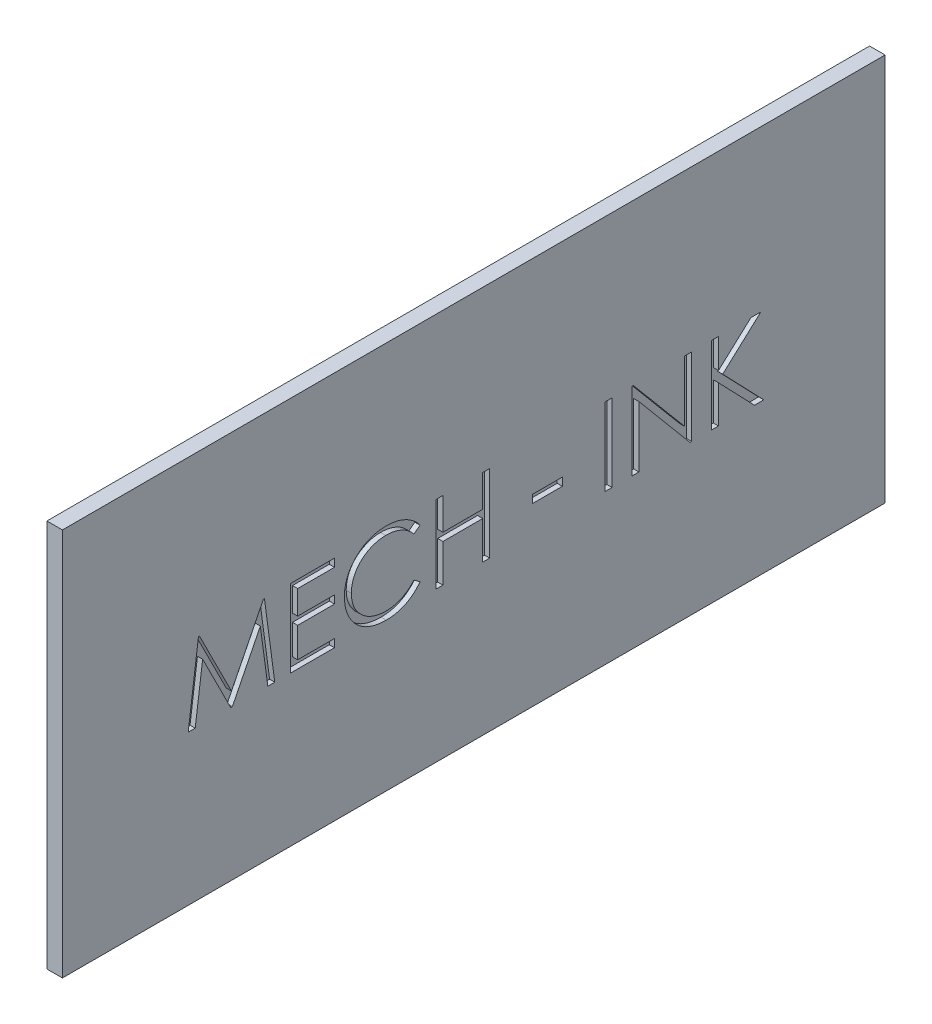
from build123d import *

# Parameters (mm, degrees)
CROQUIS1_W              = 159.01
CROQUIS1_H              = 75
SALIENTE_EXTRUIR1_DEPTH = 3
CROQUIS2_W              = 5.769230769
CROQUIS2_H              = 1.538461538
CROQUIS2_W_2            = 1.346153846
CROQUIS2_H_2            = 15
CORTAR_EXTRUIR1_DEPTH   = 1


with BuildPart() as part:
    # Croquis1 → Saliente-Extruir1 (new body)
    with BuildSketch(Plane(origin=(0, 0, 0), x_dir=(0, 0, -1), z_dir=(1, 0, 0))):
        Rectangle(CROQUIS1_W, CROQUIS1_H)
    extrude(amount=SALIENTE_EXTRUIR1_DEPTH)

    # Croquis2 → Cortar-Extruir1 (cut)
    with BuildSketch(Plane(origin=(3, 0, 0), x_dir=(0, 0, -1), z_dir=(1, 0, 0))):
        Polygon((-55.192307692, -8.506703652), (-53.212139423, 6.493296348), (-53.019831731, 6.493296348), (-46.826923077, -5.81439596), (-40.652043269, 6.493296348), (-40.459735577, 6.493296348), (-38.461538462, -8.506703652), (-39.807692308, -8.506703652), (-41.25, 2.277551155), (-46.661658654, -8.506703652), (-46.968149038, -8.506703652), (-52.403846154, 2.31060404), (-53.837139423, -8.506703652), align=None)
        Polygon((-35.384615385, 6.493296348), (-26.923076923, 6.493296348), (-26.923076923, 4.954834809), (-34.038461538, 4.954834809), (-34.038461538, 0.339450194), (-26.923076923, 0.339450194), (-26.923076923, -1.199011345), (-34.038461538, -1.199011345), (-34.038461538, -6.968242114), (-26.923076923, -6.968242114), (-26.923076923, -8.506703652), (-35.384615385, -8.506703652), align=None)
        with BuildLine():
            Line((-10.384615385, 3.740892502), (-11.5625, 2.839450194))
            add(Edge.make_bspline(
                [(-11.5625, 2.839450194), (-11.646525236, 2.939590065), (-11.813442865, 3.138519703), (-12.081982304, 3.417860608), (-12.361846488, 3.679568871), (-12.652928436, 3.924891213), (-12.96046752, 4.14524878), (-13.2770138, 4.352124936), (-13.607862565, 4.537558098), (-14.065369999, 4.762399467), (-14.663860778, 4.997025846), (-15.417267231, 5.19375398), (-16.203743367, 5.31898759), (-16.740304508, 5.332551196), (-17.013221154, 5.339450194)],
                knots=[0, 0, 0, 0, 0.757959112, 1.505699292, 2.245454638, 2.979532153, 3.711538275, 4.438200793, 5.171680507, 5.909471876, 7.393775596, 8.890124382, 10.418191784, 12, 12, 12, 12], degree=3))
            add(Edge.make_bspline(
                [(-17.013221154, 5.339450194), (-17.163578151, 5.337718926), (-17.462896691, 5.334272458), (-17.907104434, 5.288804778), (-18.34301751, 5.224899593), (-18.770352366, 5.130076779), (-19.188565045, 5.010194126), (-19.600389625, 4.866942352), (-19.999863625, 4.689707324), (-20.392513217, 4.493814781), (-20.768709835, 4.272554303), (-21.12466004, 4.031211367), (-21.459065617, 3.772486668), (-21.772191098, 3.495410498), (-22.06435659, 3.201230667), (-22.333445065, 2.88681206), (-22.578525395, 2.553159888), (-22.804455502, 2.204673856), (-23.006795788, 1.842369034), (-23.176209557, 1.464904447), (-23.326231509, 1.078744005), (-23.444942549, 0.679524744), (-23.538904764, 0.270055748), (-23.603737607, -0.150761915), (-23.648688198, -0.582049113), (-23.652117527, -0.874374738), (-23.653846154, -1.021727691)],
                knots=[0, 0, 0, 0, 1.054917814, 2.100044995, 3.131103042, 4.146048494, 5.169673617, 6.183595914, 7.203665975, 8.234915748, 9.262203917, 10.264457458, 11.251630812, 12.227803204, 13.197192746, 14.159520551, 15.12972552, 16.100847026, 17.073214652, 18.039054194, 19.002613845, 19.979014051, 20.95965708, 21.949030935, 22.966165397, 24, 24, 24, 24], degree=3))
            add(Edge.make_bspline(
                [(-23.653846154, -1.021727691), (-23.648438358, -1.243433348), (-23.637820868, -1.678722997), (-23.543328008, -2.316311328), (-23.39973476, -2.927114215), (-23.184525144, -3.50731354), (-22.919157785, -4.064063646), (-22.583840878, -4.587944446), (-22.195484289, -5.08687258), (-21.74859392, -5.549056641), (-21.25828328, -5.971258321), (-20.732220802, -6.343046528), (-20.171716712, -6.652967453), (-19.582959725, -6.910864366), (-18.961419237, -7.109107485), (-18.308212941, -7.248668014), (-17.624761533, -7.339705931), (-17.157749819, -7.348421737), (-16.920072115, -7.352857498)],
                knots=[0, 0, 0, 0, 1.029171465, 2.020641659, 2.987623507, 3.938342917, 4.889210282, 5.84687017, 6.821220943, 7.821438502, 8.827599549, 9.822697543, 10.807740252, 11.797342354, 12.80366471, 13.83203677, 14.896651826, 16, 16, 16, 16], degree=3))
            add(Edge.make_bspline(
                [(-16.920072115, -7.352857498), (-16.658203448, -7.345619871), (-16.142783267, -7.331374489), (-15.386920297, -7.210691992), (-14.663338444, -7.015015202), (-13.971998788, -6.741166963), (-13.314850304, -6.385172872), (-12.690864617, -5.95361054), (-12.099515029, -5.442374829), (-11.74392382, -5.052018565), (-11.5625, -4.852857498)],
                knots=[0, 0, 0, 0, 1.028121516, 2.023589091, 2.998037872, 3.967518031, 4.937445131, 5.927275754, 6.942489185, 8, 8, 8, 8], degree=3))
            Line((-11.5625, -4.852857498), (-10.384615385, -5.745285383))
            add(Edge.make_bspline(
                [(-10.384615385, -5.745285383), (-10.479407284, -5.867593034), (-10.668537035, -6.11162249), (-10.974785679, -6.455644103), (-11.297402668, -6.779232826), (-11.638784283, -7.079779774), (-11.995003389, -7.363298913), (-12.372456157, -7.621735333), (-12.766180582, -7.858696265), (-13.174842634, -8.075668799), (-13.598008118, -8.268171286), (-14.035169982, -8.432973148), (-14.484443877, -8.57493696), (-14.945850341, -8.691730975), (-15.420346442, -8.782892763), (-15.906219902, -8.843834226), (-16.404519368, -8.885585288), (-16.740696887, -8.889390642), (-16.911057692, -8.891319037)],
                knots=[0, 0, 0, 0, 0.986787822, 1.968848986, 2.935600012, 3.899624008, 4.868462664, 5.837806735, 6.815139263, 7.798259679, 8.787526145, 9.778297419, 10.776456485, 11.791383307, 12.812564526, 13.85620153, 14.913611965, 16, 16, 16, 16], degree=3))
            add(Edge.make_bspline(
                [(-16.911057692, -8.891319037), (-17.072387694, -8.890196212), (-17.391397794, -8.887975964), (-17.862392444, -8.852009532), (-18.320919219, -8.802939231), (-18.765667616, -8.729052955), (-19.199064652, -8.641862926), (-19.617181442, -8.524986112), (-20.024132344, -8.394061112), (-20.418282375, -8.240182598), (-20.799966803, -8.066541816), (-21.167954566, -7.870292277), (-21.522076419, -7.653084286), (-21.865813937, -7.41970567), (-22.194089296, -7.16266009), (-22.509747261, -6.885517371), (-22.814557874, -6.589211611), (-23.00314081, -6.375547954), (-23.097956731, -6.268121922)],
                knots=[0, 0, 0, 0, 1.114604814, 2.203992996, 3.262667896, 4.300477797, 5.318619304, 6.316056647, 7.298880507, 8.271930387, 9.238335007, 10.195173496, 11.151986948, 12.108099108, 13.064862484, 14.031167946, 15.010108607, 16, 16, 16, 16], degree=3))
            add(Edge.make_bspline(
                [(-23.097956731, -6.268121922), (-23.249823774, -6.081516826), (-23.551724389, -5.710559496), (-23.937977319, -5.109333862), (-24.268609698, -4.481612967), (-24.535935073, -3.824098986), (-24.744918215, -3.138267327), (-24.889694765, -2.423772265), (-24.98377307, -1.681281084), (-24.994531451, -1.176266275), (-25, -0.919564229)],
                knots=[0, 0, 0, 0, 0.994628077, 1.977248131, 2.950237994, 3.925870899, 4.908910175, 5.911660606, 6.938484602, 8, 8, 8, 8], degree=3))
            add(Edge.make_bspline(
                [(-25, -0.919564229), (-24.993334885, -0.649755143), (-24.980221687, -0.118922609), (-24.868811135, 0.66010862), (-24.689587722, 1.406471758), (-24.435029628, 2.11877352), (-24.112292408, 2.800760435), (-23.713606921, 3.447222742), (-23.243604883, 4.06229474), (-22.70597245, 4.636643674), (-22.116398155, 5.161812329), (-21.48503181, 5.623838916), (-20.81310918, 6.008342556), (-20.108032673, 6.329754681), (-19.364522609, 6.57680238), (-18.584165313, 6.749744609), (-17.768427107, 6.857389393), (-17.211873854, 6.870997427), (-16.929086538, 6.877911732)],
                knots=[0, 0, 0, 0, 1.032925535, 2.032216505, 3.007276963, 3.968222605, 4.92396291, 5.891752235, 6.871517503, 7.883894988, 8.900124299, 9.891468569, 10.874487609, 11.85992873, 12.854644235, 13.869047385, 14.917252991, 16, 16, 16, 16], degree=3))
            add(Edge.make_bspline(
                [(-16.929086538, 6.877911732), (-16.756738802, 6.875845426), (-16.415593813, 6.87175538), (-15.910939589, 6.831871914), (-15.41961533, 6.76538503), (-14.94128255, 6.674887588), (-14.473614195, 6.562570496), (-14.020184591, 6.416254932), (-13.578333076, 6.248955512), (-13.150846327, 6.056276372), (-12.739775397, 5.839990337), (-12.345248318, 5.602494808), (-11.970398924, 5.344084213), (-11.612589573, 5.066956318), (-11.277805811, 4.765248207), (-10.956542332, 4.44725851), (-10.65970914, 4.103827835), (-10.476481161, 3.862092404), (-10.384615385, 3.740892502)],
                knots=[0, 0, 0, 0, 1.096760587, 2.17092713, 3.219439832, 4.250915756, 5.268269357, 6.278326846, 7.281116186, 8.274029601, 9.260640565, 10.235837813, 11.203064059, 12.156899882, 13.114053108, 14.069676657, 15.032185724, 16, 16, 16, 16], degree=3))
        make_face()
        Polygon((-7.307692308, 6.493296348), (-5.961538462, 6.493296348), (-5.961538462, 0.339450194), (1.730769231, 0.339450194), (1.730769231, 6.493296348), (3.076923077, 6.493296348), (3.076923077, -8.506703652), (1.730769231, -8.506703652), (1.730769231, -1.199011345), (-5.961538462, -1.199011345), (-5.961538462, -8.506703652), (-7.307692308, -8.506703652), align=None)
        with Locations((14.23076923, -2.737472883)):
            Rectangle(CROQUIS2_W, CROQUIS2_H)
        with Locations((26.057692308, -1.006703652)):
            Rectangle(CROQUIS2_W_2, CROQUIS2_H_2)
        Polygon((30.576923077, -8.506703652), (30.576923077, 6.493296348), (30.859375, 6.493296348), (40.769230769, -5.312593075), (40.769230769, 6.493296348), (42.115384615, 6.493296348), (42.115384615, -8.506703652), (41.808894231, -8.506703652), (31.923076923, 3.272142502), (31.923076923, -8.506703652), align=None)
        Polygon((45.961538462, 6.493296348), (47.307692308, 6.493296348), (47.307692308, 0.781156925), (53.560697115, 6.493296348), (55.480769231, 6.493296348), (48.109975962, -0.237472883), (56.057692308, -8.506703652), (54.260817308, -8.506703652), (47.307692308, -1.268121922), (47.307692308, -8.506703652), (45.961538462, -8.506703652), align=None)
    extrude(amount=-CORTAR_EXTRUIR1_DEPTH, mode=Mode.SUBTRACT)


solid = part.part
